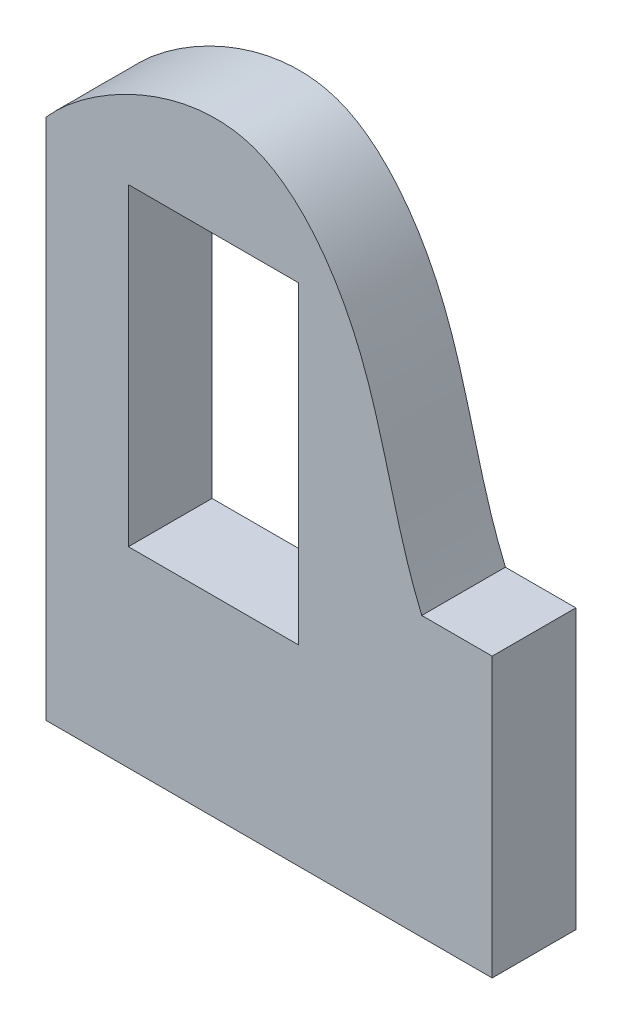
from build123d import *

# Parameters (mm, degrees)
SKETCH1_W           = 64
SKETCH1_H           = 40
BOSS_EXTRUDE1_DEPTH = 12
SKETCH2_W           = 24.4
SKETCH2_H           = 45
CUT_EXTRUDE1_DEPTH  = 20


with BuildPart() as part:
    # Sketch1 → Boss-Extrude1 (new body)
    with BuildSketch(Plane.XY):
        with BuildLine():
            Line((-32, 55), (-32, 20))
            Line((-32, 20), (21.894736842, 20))
            add(Edge.make_bspline(
                [(-32, 55), (-26.093097091, 61.828307886), (-5.103314892, 73.642536114), (16.062213436, 49.100660173), (17.060908408, 31.40349279), (21.894736842, 20)],
                knots=[0, 0, 0, 0, 0.381160141, 0.579099432, 1, 1, 1, 1], degree=3))
        make_face()
        Rectangle(SKETCH1_W, SKETCH1_H)
    extrude(amount=BOSS_EXTRUDE1_DEPTH)

    # Sketch2 → Cut-Extrude1 (cut)
    with BuildSketch(Plane.XY.offset(12)):
        with Locations((-8, 30)):
            Rectangle(SKETCH2_W, SKETCH2_H)
    extrude(amount=-CUT_EXTRUDE1_DEPTH, mode=Mode.SUBTRACT)


solid = part.part
